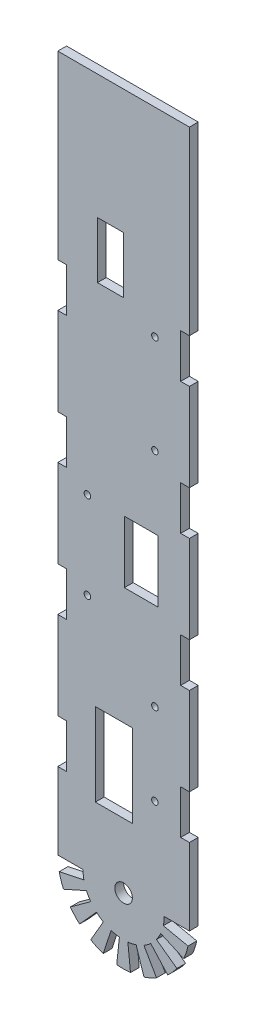
from build123d import *

# Parameters (mm, degrees)
SKETCH1_R           = 1.5
SKETCH1_R_2         = 4
SKETCH1_W           = 11.924742873
SKETCH1_H           = 25.690658486
SKETCH1_W_2         = 15.264959333
SKETCH1_H_2         = 28.225795916
SKETCH1_W_3         = 16.875415016
SKETCH1_H_3         = 37.724658957
BOSS_EXTRUDE1_DEPTH = 4


with BuildPart() as part:
    # Sketch1 → Boss-Extrude1 (new body)
    with BuildSketch(Plane.XY):
        with BuildLine():
            Line((-30, 34.937585281), (-30, 0))
            Line((-30, 0), (-18.5, 0))
            ThreePointArc((-18.5, 0), (-18.398655064, -1.93377657), (-18.095730614, -3.84636628))
            Line((-18.095730614, -3.84636628), (-29.344428022, -6.237350725))
            ThreePointArc((-29.344428022, -6.237350725), (-28.531695489, -9.270509831), (-27.406363729, -12.202099292))
            Line((-27.406363729, -12.202099292), (-16.900590966, -7.524627897))
            ThreePointArc((-16.900590966, -7.524627897), (-16.02146997, -9.25), (-14.966814396, -10.874027167))
            Line((-14.966814396, -10.874027167), (-24.270509831, -17.633557569))
            ThreePointArc((-24.270509831, -17.633557569), (-22.294344764, -20.073918191), (-20.073918191, -22.294344764))
            Line((-20.073918191, -22.294344764), (-12.378916218, -13.748179271))
            ThreePointArc((-12.378916218, -13.748179271), (-10.874027167, -14.966814396), (-9.25, -16.02146997))
            Line((-9.25, -16.02146997), (-15, -25.980762114))
            ThreePointArc((-15, -25.980762114), (-12.202099292, -27.406363729), (-9.270509831, -28.531695489))
            Line((-9.270509831, -28.531695489), (-5.716814396, -17.594545551))
            ThreePointArc((-5.716814396, -17.594545551), (-3.84636628, -18.095730614), (-1.93377657, -18.398655064))
            Line((-1.93377657, -18.398655064), (-3.135853898, -29.835656861))
            ThreePointArc((-3.135853898, -29.835656861), (0, -30), (3.135853898, -29.835656861))
            Line((3.135853898, -29.835656861), (1.93377657, -18.398655064))
            ThreePointArc((1.93377657, -18.398655064), (3.84636628, -18.095730614), (5.716814396, -17.594545551))
            Line((5.716814396, -17.594545551), (9.270509831, -28.531695489))
            ThreePointArc((9.270509831, -28.531695489), (12.202099292, -27.406363729), (15, -25.980762114))
            Line((15, -25.980762114), (9.25, -16.02146997))
            ThreePointArc((9.25, -16.02146997), (10.874027167, -14.966814396), (12.378916218, -13.748179271))
            Line((12.378916218, -13.748179271), (20.073918191, -22.294344764))
            ThreePointArc((20.073918191, -22.294344764), (22.294344764, -20.073918191), (24.270509831, -17.633557569))
            Line((24.270509831, -17.633557569), (14.966814396, -10.874027167))
            ThreePointArc((14.966814396, -10.874027167), (16.02146997, -9.25), (16.900590966, -7.524627897))
            Line((16.900590966, -7.524627897), (27.406363729, -12.202099292))
            ThreePointArc((27.406363729, -12.202099292), (28.531695489, -9.270509831), (29.344428022, -6.237350725))
            Line((29.344428022, -6.237350725), (18.095730614, -3.84636628))
            ThreePointArc((18.095730614, -3.84636628), (18.398655064, -1.93377657), (18.5, 0))
            Line((18.5, 0), (30, 0))
            Line((30, 0), (30, 34.937585281))
            Line((30, 34.937585281), (26, 34.935484554))
            Line((26, 34.935484554), (26, 54.935484554))
            Line((26, 54.935484554), (30, 54.937585281))
            Line((30, 54.937585281), (30, 94.937585281))
            Line((30, 94.937585281), (26, 94.935484554))
            Line((26, 94.935484554), (26, 114.935484554))
            Line((26, 114.935484554), (30, 114.937585281))
            Line((30, 114.937585281), (30, 154.937585281))
            Line((30, 154.937585281), (26, 154.935484554))
            Line((26, 154.935484554), (26, 174.935484554))
            Line((26, 174.935484554), (30, 174.937585281))
            Line((30, 174.937585281), (30, 214.937585281))
            Line((30, 214.937585281), (26, 214.935484554))
            Line((26, 214.935484554), (26, 234.935484554))
            Line((26, 234.935484554), (30, 234.937585281))
            Line((30, 234.937585281), (30, 317.280454818))
            Line((30, 317.280454818), (-30, 317.280454818))
            Line((-30, 317.280454818), (-30, 234.937585281))
            Line((-30, 234.937585281), (-26, 234.935484554))
            Line((-26, 234.935484554), (-26, 214.935484554))
            Line((-26, 214.935484554), (-30, 214.937585281))
            Line((-30, 214.937585281), (-30, 174.937585281))
            Line((-30, 174.937585281), (-26, 174.935484554))
            Line((-26, 174.935484554), (-26, 154.935484554))
            Line((-26, 154.935484554), (-30, 154.937585281))
            Line((-30, 154.937585281), (-30, 114.937585281))
            Line((-30, 114.937585281), (-26, 114.935484554))
            Line((-26, 114.935484554), (-26, 94.935484554))
            Line((-26, 94.935484554), (-30, 94.937585281))
            Line((-30, 94.937585281), (-30, 54.937585281))
            Line((-30, 54.937585281), (-26, 54.935484554))
            Line((-26, 54.935484554), (-26, 34.935484554))
            Line((-26, 34.935484554), (-30, 34.937585281))
        make_face()
        with Locations((14.272904268, 226.626719074)):
            Circle(SKETCH1_R, mode=Mode.SUBTRACT)
        Circle(SKETCH1_R_2, mode=Mode.SUBTRACT)
        with Locations((14.272904268, 181.743471487)):
            Circle(SKETCH1_R, mode=Mode.SUBTRACT)
        with Locations((-16.5, 148.898926565)):
            Circle(SKETCH1_R, mode=Mode.SUBTRACT)
        with Locations((-16.5, 109.235963151)):
            Circle(SKETCH1_R, mode=Mode.SUBTRACT)
        with Locations((14.272904268, 80.661965153)):
            Circle(SKETCH1_R, mode=Mode.SUBTRACT)
        with Locations((14.272904268, 43.392817663)):
            Circle(SKETCH1_R, mode=Mode.SUBTRACT)
        with Locations((-5.962371437, 247.780813797)):
            Rectangle(SKETCH1_W, SKETCH1_H, mode=Mode.SUBTRACT)
        with Locations((7.963115834, 134.786028607)):
            Rectangle(SKETCH1_W_2, SKETCH1_H_2, mode=Mode.SUBTRACT)
        with Locations((-4.437707508, 48.307901028)):
            Rectangle(SKETCH1_W_3, SKETCH1_H_3, mode=Mode.SUBTRACT)
    extrude(amount=BOSS_EXTRUDE1_DEPTH)


solid = part.part
